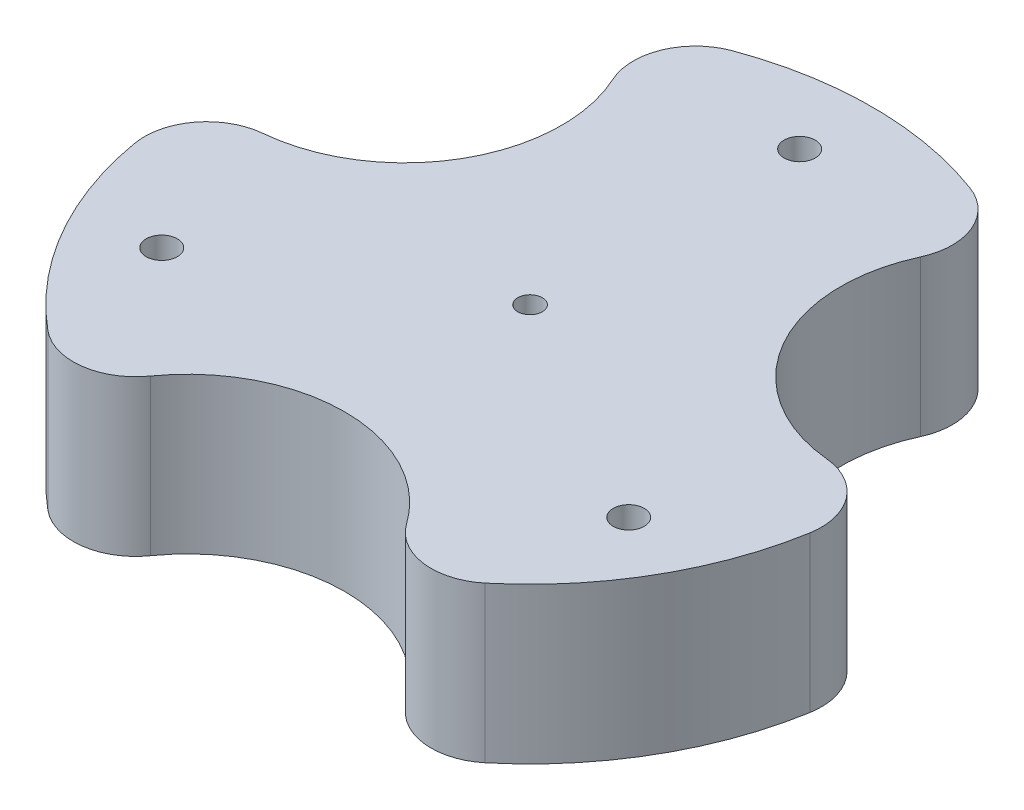
from build123d import *

# Parameters (mm, degrees)
SKETCH1_R                       = 13.97
BOSS_EXTRUDE1_DEPTH             = 6.35
SKETCH2_R                       = 0.635
CUT_EXTRUDE1_DEPTH              = 21.751970991
CIRPATTERN1_COUNT               = 3
SKETCH4_R                       = 6.406839675
CUT_EXTRUDE3_DEPTH              = 21.751970991
CIRPATTERN2_COUNT               = 3
FILLET1_R                       = 2.54
F_1_0MM_PRESS_DOWEL_HOLE1_D     = 1
F_1_0MM_PRESS_DOWEL_HOLE1_DEPTH = 24.892
F_1_0MM_PRESS_DOWEL_HOLE1_TIP   = 0.30043031


with BuildPart() as part:
    # Sketch1 → Boss-Extrude1 (new body)
    with BuildSketch(Plane(origin=(0, 0, 0), x_dir=(1, 0, 0), z_dir=(0, 1, 0))):
        Circle(SKETCH1_R)
    extrude(amount=BOSS_EXTRUDE1_DEPTH)

    # Sketch2 → Cut-Extrude1 (cut, through all)
    with BuildSketch(Plane(origin=(0, 6.35, 0), x_dir=(1, 0, 0), z_dir=(0, 1, 0))):
        with Locations((0, 11)):
            Circle(SKETCH2_R)
    cut_extrude1 = extrude(amount=-CUT_EXTRUDE1_DEPTH, mode=Mode.SUBTRACT)

    # CirPattern1: Cut-Extrude1 ×3 about axis
    cirpattern1_axis = Axis((0, 6.35, 0), (0, -1, 0))
    for i in range(1, CIRPATTERN1_COUNT):
        add(cut_extrude1.rotate(cirpattern1_axis, i * 360 / CIRPATTERN1_COUNT), mode=Mode.SUBTRACT)

    # Sketch4 → Cut-Extrude3 (cut, through all)
    with BuildSketch(Plane(origin=(0, 6.35, 0), x_dir=(1, 0, 0), z_dir=(0, 1, 0))):
        with Locations((0, -13.97)):
            Circle(SKETCH4_R)
    cut_extrude3 = extrude(amount=-CUT_EXTRUDE3_DEPTH, mode=Mode.SUBTRACT)

    # CirPattern2: Cut-Extrude3 ×3 about axis
    cirpattern2_axis = Axis((0, 6.35, 0), (0, -1, 0))
    for i in range(1, CIRPATTERN2_COUNT):
        add(cut_extrude3.rotate(cirpattern2_axis, i * 360 / CIRPATTERN2_COUNT), mode=Mode.SUBTRACT)

    # Fillet1
    fillet1_edges = [part.edges().sort_by_distance(p)[0] for p in [
        (13.944129749, 3.175, -0.849791477),
        (6.236123867, 3.175, 12.500866334),
        (-6.236123867, 3.175, 12.500866334),
        (-13.944129749, 3.175, -0.849791477),
        (-7.708005881, 3.175, -11.651074857),
        (7.708005881, 3.175, -11.651074857),
    ]]
    fillet(fillet1_edges, radius=FILLET1_R)

    # Ø1.0mm Press Dowel Hole1
    with Locations(Plane(origin=(0, 6.35, 0), x_dir=(1, 0, 0), z_dir=(0, 1, 0))):
        with Locations((0, 0)):
            Hole(F_1_0MM_PRESS_DOWEL_HOLE1_D / 2, depth=F_1_0MM_PRESS_DOWEL_HOLE1_DEPTH)
            with Locations((0, 0, -(F_1_0MM_PRESS_DOWEL_HOLE1_DEPTH + F_1_0MM_PRESS_DOWEL_HOLE1_TIP / 2))):  # 118° drill point
                Cone(0, F_1_0MM_PRESS_DOWEL_HOLE1_D / 2, F_1_0MM_PRESS_DOWEL_HOLE1_TIP, mode=Mode.SUBTRACT)


solid = part.part
